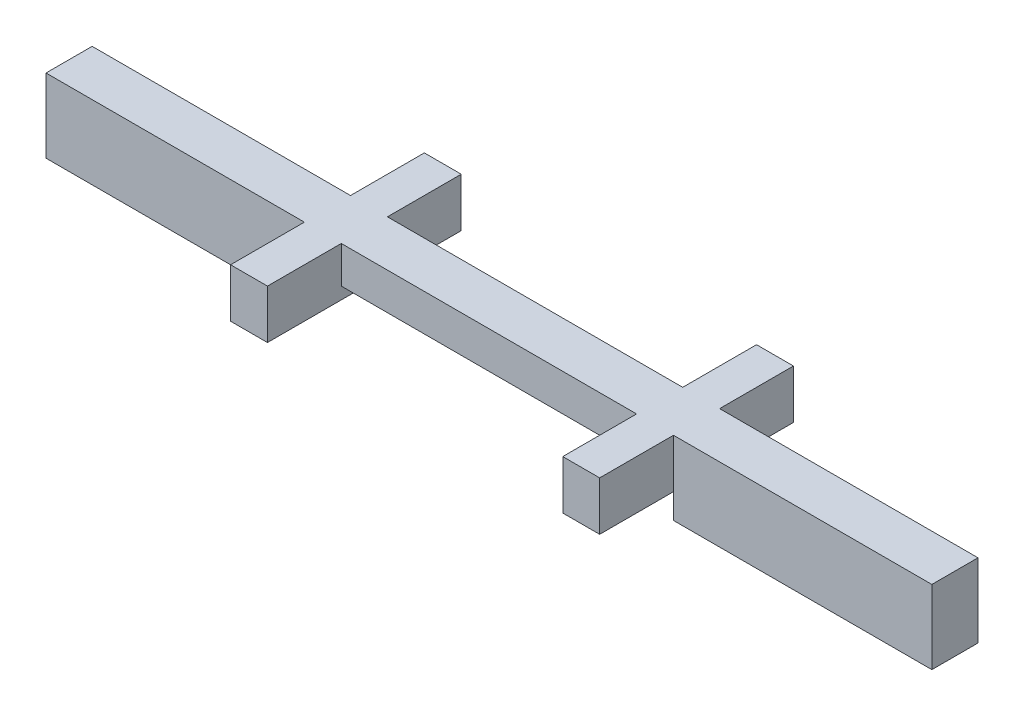
from build123d import *

# Parameters (mm, degrees)
BOSS_EXTRUDE1_DEPTH = 1.25
SKETCH4_W           = 1
SKETCH4_H           = 1.325
BOSS_EXTRUDE4_DEPTH = 2
SKETCH5_W           = 1
SKETCH5_H           = 1.325
BOSS_EXTRUDE5_DEPTH = 2


with BuildPart() as part:
    # Sketch1 → Boss-Extrude1 (new body)
    with BuildSketch(Plane.XY):
        Polygon((1, 0), (9, 0), (9, -0.325), (10, -0.325), (10, -1), (17, -1), (17, 1), (10, 1), (0, 1), (-7, 1), (-7, -1), (0, -1), (0, -0.325), (1, -0.325), align=None)
    extrude(amount=BOSS_EXTRUDE1_DEPTH)

    # Sketch4 → Boss-Extrude4 (add)
    with BuildSketch(Plane(origin=(0, 0, 0), x_dir=(-1, 0, 0), z_dir=(0, 0, -1))):
        with Locations((-9.5, 0.3375)):
            Rectangle(SKETCH4_W, SKETCH4_H)
        with Locations((-0.5, 0.3375)):
            Rectangle(SKETCH4_W, SKETCH4_H)
    extrude(amount=BOSS_EXTRUDE4_DEPTH)

    # Sketch5 → Boss-Extrude5 (add)
    with BuildSketch(Plane.XY.offset(1.25)):
        with Locations((0.5, 0.3375)):
            Rectangle(SKETCH5_W, SKETCH5_H)
        with Locations((9.5, 0.3375)):
            Rectangle(SKETCH5_W, SKETCH5_H)
    extrude(amount=BOSS_EXTRUDE5_DEPTH)


solid = part.part
